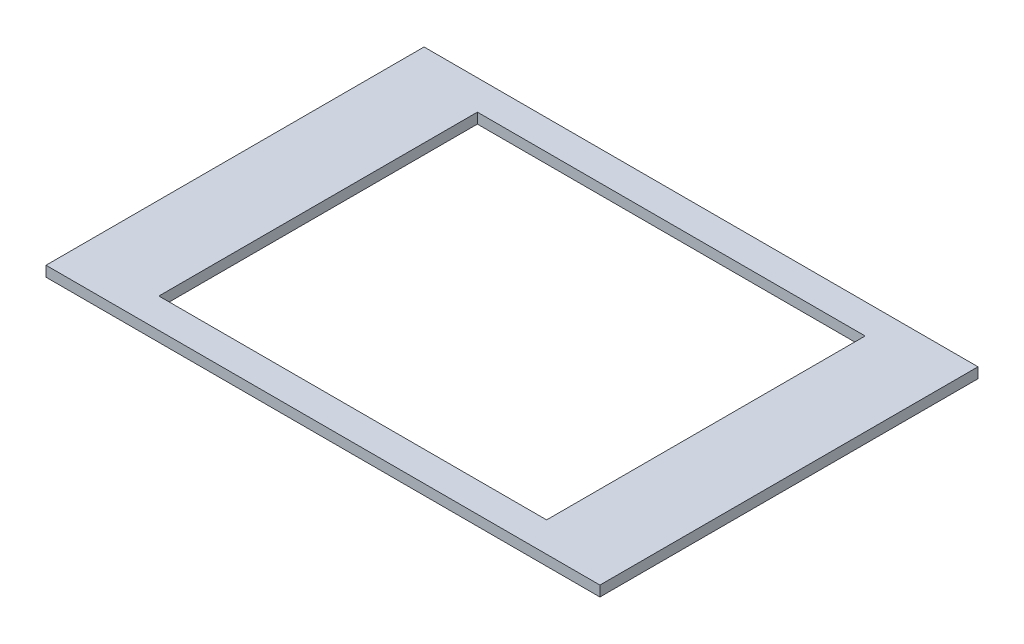
from build123d import *

# Parameters (mm, degrees)
SKETCH1_W           = 254
SKETCH1_H           = 173.355
SKETCH1_W_2         = 177.8
SKETCH1_H_2         = 146.05
BOSS_EXTRUDE1_DEPTH = 4.7625


with BuildPart() as part:
    # Sketch1 → Boss-Extrude1 (new body)
    with BuildSketch(Plane(origin=(0, 0, 0), x_dir=(1, 0, 0), z_dir=(0, 1, 0))):
        Rectangle(SKETCH1_W, SKETCH1_H)
        Rectangle(SKETCH1_W_2, SKETCH1_H_2, mode=Mode.SUBTRACT)
    extrude(amount=BOSS_EXTRUDE1_DEPTH)


solid = part.part
